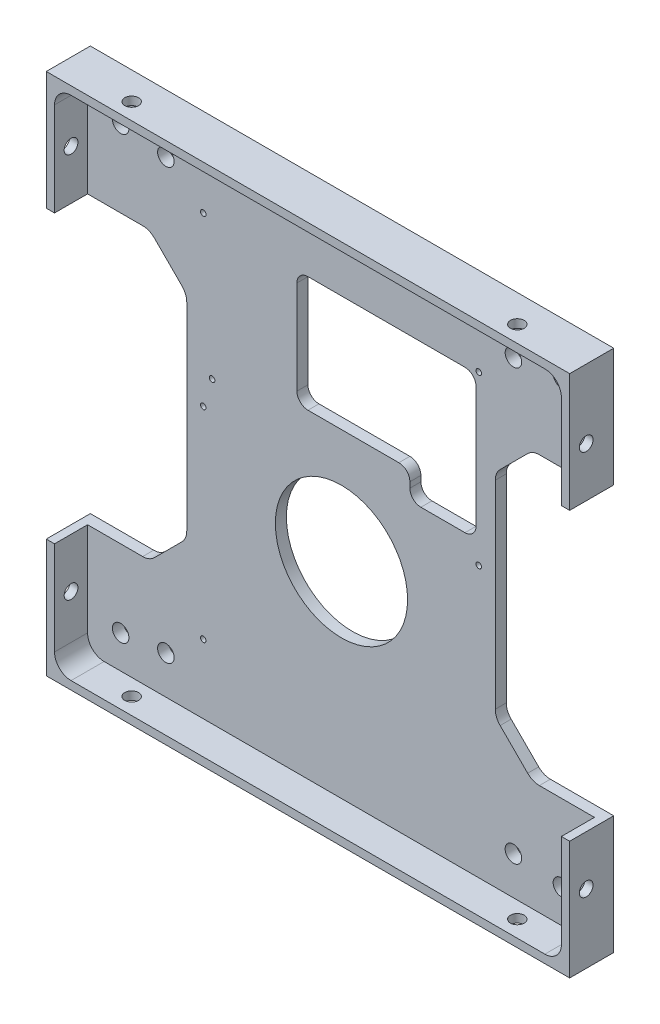
from build123d import *

# Parameters (mm, degrees)
SKETCH1_W                      = 96
SKETCH1_H                      = 96
BOSS_EXTRUDE1_DEPTH            = 8
SKETCH2_W                      = 92
SKETCH2_H                      = 92
COMPONENT_PLATFORM_DEPTH       = 6
CABLE_SLOTS_DEPTH              = 6
INNER_CORNER_FILLETS_R         = 3
M3X0_5_TAPPED_HOLE1_AT_2_COUNT = 2
M3X0_5_TAPPED_HOLE1_AT_2_PITCH = 70
M3X0_5_TAPPED_HOLE2_AT_2_COUNT = 2
M3X0_5_TAPPED_HOLE2_AT_2_PITCH = 70
SKETCH29_R                     = 12
HDD_EXTRUSION_CUTOUT_DEPTH     = 10
HDD_EXTRUSION_CUTOUT_2_DEPTH   = 10
F_3_0MM_DOWEL_HOLE1_D          = 3
F_3_0MM_DOWEL_HOLE1_DEPTH      = 2
F_3_0MM_DOWEL_HOLE2_D          = 3
CUT_EXTRUDE1_START             = -8
SKETCH35_OUTSIDE_W             = 125.2
SKETCH35_OUTSIDE_H             = 125.2
SKETCH35_OUTSIDE_W_2           = 95
SKETCH35_OUTSIDE_H_2           = 95
CUT_EXTRUDE1_DEPTH             = 8
M1_6_CLEARANCE_HOLE2_D         = 1


with BuildPart() as part:
    # Sketch1 → Boss-Extrude1 (new body)
    with BuildSketch(Plane.XY):
        Rectangle(SKETCH1_W, SKETCH1_H)
    extrude(amount=BOSS_EXTRUDE1_DEPTH)

    # Sketch2 → Component Platform (cut)
    with BuildSketch(Plane.XY.offset(8)):
        Rectangle(SKETCH2_W, SKETCH2_H)
    extrude(amount=-COMPONENT_PLATFORM_DEPTH, mode=Mode.SUBTRACT)

    # Sketch3 → Cable Slots (cut, symmetric)
    with BuildSketch(Plane.XY.offset(2)):
        with BuildLine():
            Line((-33.878679656, -25.121320344), (-28.878679656, -20.121320344))
            ThreePointArc((-28.878679656, -20.121320344), (-28.228361402, -19.148050297), (-28, -18))
            Line((-28, -18), (-28, 18))
            ThreePointArc((-28, 18), (-28.228361402, 19.148050297), (-28.878679656, 20.121320344))
            Line((-28.878679656, 20.121320344), (-33.878679656, 25.121320344))
            ThreePointArc((-33.878679656, 25.121320344), (-34.851949703, 25.771638598), (-36, 26))
            Line((-36, 26), (-48, 26))
            Line((-48, 26), (-48, -26))
            Line((-48, -26), (-36, -26))
            ThreePointArc((-36, -26), (-34.851949703, -25.771638598), (-33.878679656, -25.121320344))
        make_face()
        with BuildLine():
            Line((48, -26), (48, 26))
            Line((48, 26), (36, 26))
            ThreePointArc((36, 26), (34.851949703, 25.771638598), (33.878679656, 25.121320344))
            Line((33.878679656, 25.121320344), (28.878679656, 20.121320344))
            ThreePointArc((28.878679656, 20.121320344), (28.228361402, 19.148050297), (28, 18))
            Line((28, 18), (28, -18))
            ThreePointArc((28, -18), (28.228361402, -19.148050297), (28.878679656, -20.121320344))
            Line((28.878679656, -20.121320344), (33.878679656, -25.121320344))
            ThreePointArc((33.878679656, -25.121320344), (34.851949703, -25.771638598), (36, -26))
            Line((36, -26), (48, -26))
        make_face()
    extrude(amount=CABLE_SLOTS_DEPTH, both=True, mode=Mode.SUBTRACT)

    # Inner Corner Fillets
    inner_corner_fillets_edges = [part.edges().sort_by_distance(p)[0] for p in [
        (-46, -46, 5),
        (-46, 46, 5),
        (46, 46, 5),
        (46, -46, 5),
    ]]
    fillet(inner_corner_fillets_edges, radius=INNER_CORNER_FILLETS_R)

    # Sketch14 → M3x0.5 Tapped Hole1 (revolve, cut)
    with BuildSketch(Plane(origin=(48, -35, 5), x_dir=(0, 0, -1), z_dir=(0, 1, 0))):
        Polygon((0, 0), (0, 10.751075774), (1.25, 10), (1.25, 0), align=None)
    m3x0_5_tapped_hole1 = revolve(axis=Axis((54.35, -35, 5), (-1, 0, 0)), mode=Mode.SUBTRACT)

    # M3x0.5 Tapped Hole1 at 2: M3x0.5 Tapped Hole1 ×2
    with Locations(*[(0, i * M3X0_5_TAPPED_HOLE1_AT_2_PITCH, 0) for i in range(1, M3X0_5_TAPPED_HOLE1_AT_2_COUNT)]):
        add(m3x0_5_tapped_hole1, mode=Mode.SUBTRACT)

    # Sketch16 → M3x0.5 Tapped Hole2 (revolve, cut)
    with BuildSketch(Plane(origin=(35, 48, 5), x_dir=(0, 0, 1), z_dir=(1, 0, 0))):
        Polygon((0, 0), (0, 10.751075774), (1.25, 10), (1.25, 0), align=None)
    m3x0_5_tapped_hole2 = revolve(axis=Axis((35, 54.35, 5), (0, -1, 0)), mode=Mode.SUBTRACT)

    # M3x0.5 Tapped Hole2 at 2: M3x0.5 Tapped Hole2 ×2
    with Locations(*[(-i * M3X0_5_TAPPED_HOLE2_AT_2_PITCH, 0, 0) for i in range(1, M3X0_5_TAPPED_HOLE2_AT_2_COUNT)]):
        add(m3x0_5_tapped_hole2, mode=Mode.SUBTRACT)

    # Mirror1: M3x0.5 Tapped Hole1 across plane
    add(m3x0_5_tapped_hole1.mirror(Plane(origin=(0, 0, 0), x_dir=(0, 0, 1), z_dir=(1, 0, 0))), mode=Mode.SUBTRACT)

    # Mirror1 copy 1 sketch → Mirror1 copy 1 (revolve, cut)
    with BuildSketch(Plane(origin=(-48, 35, 5), x_dir=(0, 0, -1), z_dir=(0, 1, 0))):
        Polygon((0, 0), (0, -10.751075774), (1.25, -10), (1.25, 0), align=None)
    revolve(axis=Axis((-54.35, 35, 5), (-1, 0, 0)), mode=Mode.SUBTRACT)

    # Mirror2: M3x0.5 Tapped Hole2 across plane
    add(m3x0_5_tapped_hole2.mirror(Plane(origin=(0, 0, 0), x_dir=(0, 0, 1), z_dir=(0, -1, 0))), mode=Mode.SUBTRACT)

    # Mirror2 copy 1 sketch → Mirror2 copy 1 (revolve, cut)
    with BuildSketch(Plane(origin=(-35, -48, 5), x_dir=(0, 0, 1), z_dir=(1, 0, 0))):
        Polygon((0, 0), (0, -10.751075774), (1.25, -10), (1.25, 0), align=None)
    revolve(axis=Axis((-35, -54.35, 5), (0, -1, 0)), mode=Mode.SUBTRACT)

    # Sketch29 → HDD Extrusion Cutout (cut)
    with BuildSketch(Plane(origin=(0, 0, 0), x_dir=(-1, 0, 0), z_dir=(0, 0, -1))):
        with Locations((-0.08192631, -8.74785827)):
            Circle(SKETCH29_R)
    extrude(amount=-HDD_EXTRUSION_CUTOUT_DEPTH, mode=Mode.SUBTRACT)

    # Sketch9 → HDD Extrusion Cutout 2 (cut)
    with BuildSketch(Plane.XY.offset(2)):
        with BuildLine():
            Line((24.5, 31), (24.5, 9))
            ThreePointArc((24.5, 9), (23.914213562, 7.585786438), (22.5, 7))
            Line((22.5, 7), (14.5, 7))
            ThreePointArc((14.5, 7), (13.085786438, 7.585786438), (12.5, 9))
            Line((12.5, 9), (12.5, 10))
            ThreePointArc((12.5, 10), (11.914213562, 11.414213562), (10.5, 12))
            Line((10.5, 12), (-6, 12))
            ThreePointArc((-6, 12), (-7.414213562, 12.585786438), (-8, 14))
            Line((-8, 14), (-8, 31))
            ThreePointArc((-8, 31), (-7.414213562, 32.414213562), (-6, 33))
            Line((-6, 33), (22.5, 33))
            ThreePointArc((22.5, 33), (23.914213562, 32.414213562), (24.5, 31))
        make_face()
    extrude(amount=-HDD_EXTRUSION_CUTOUT_2_DEPTH, mode=Mode.SUBTRACT)

    # Ø3.0mm Dowel Hole1
    with Locations(Plane.XY.offset(2)):
        with Locations((-31.790998517, -39.06), (31.29001483, -39.06), (31.29001483, 38.94), (-31.790998517, 38.94)):
            Hole(F_3_0MM_DOWEL_HOLE1_D / 2, depth=F_3_0MM_DOWEL_HOLE1_DEPTH)

    # Ø3.0mm Dowel Hole2 (through all)
    with Locations(Plane.XY.offset(2)):
        with Locations((40, -40), (-40, -40), (-40, 40), (40, 40)):
            Hole(F_3_0MM_DOWEL_HOLE2_D / 2)

    # Sketch35 outside → Cut-Extrude1 (cut)
    with BuildSketch(Plane(origin=(0, 0, 0), x_dir=(-1, 0, 0), z_dir=(0, 0, -1)).offset(CUT_EXTRUDE1_START)):
        Rectangle(SKETCH35_OUTSIDE_W, SKETCH35_OUTSIDE_H)
        Rectangle(SKETCH35_OUTSIDE_W_2, SKETCH35_OUTSIDE_H_2, mode=Mode.SUBTRACT)
    extrude(amount=CUT_EXTRUDE1_DEPTH, mode=Mode.SUBTRACT)

    # M1.6 Clearance Hole2 (through all)
    with Locations(Plane(origin=(-25, -33.5, 2), x_dir=(1, 0, 0), z_dir=(0, 0, 1))):
        with Locations((0, 0), (0, 36.6), (1.6, 41.7), (0, 67), (50, 67), (50, 36.6)):
            Hole(M1_6_CLEARANCE_HOLE2_D / 2)


solid = part.part
